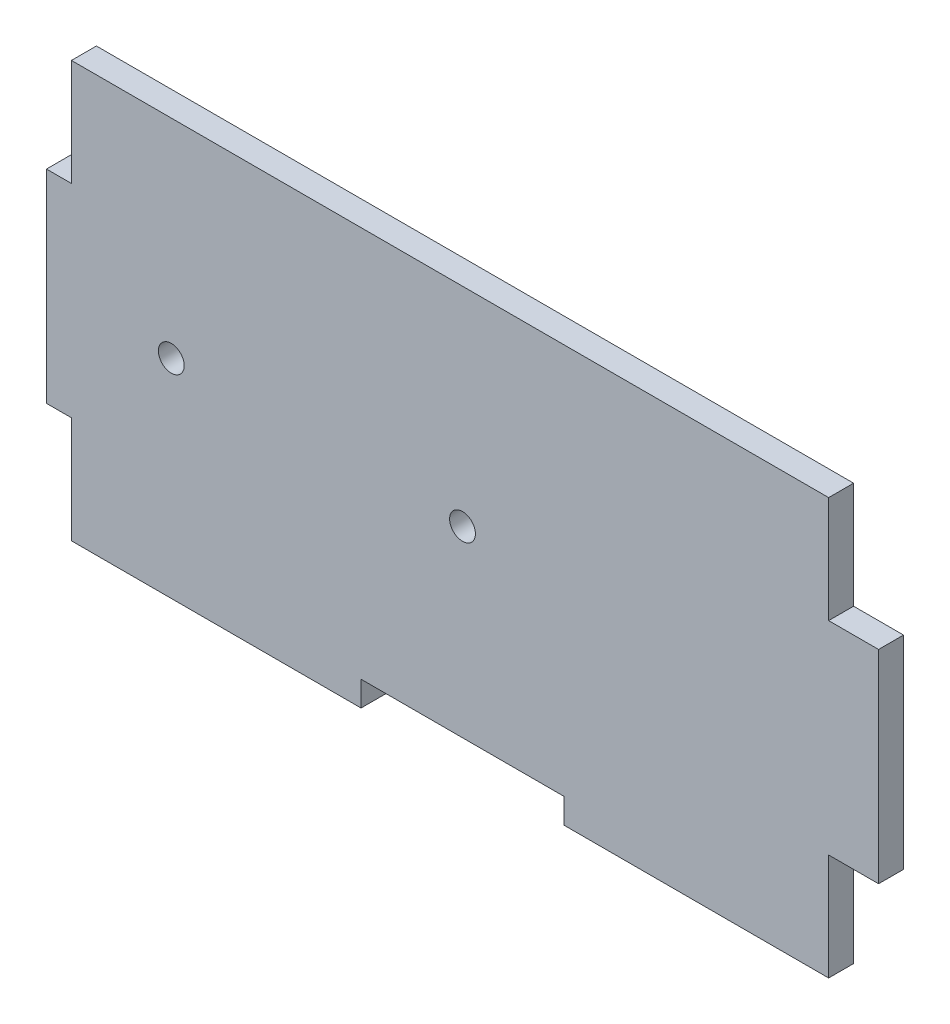
from build123d import *

# Parameters (mm, degrees)
SALIENTE_EXTRUIR1_DEPTH = 3
CROQUIS2_R              = 1.55
CORTAR_EXTRUIR1_DEPTH   = 3
CROQUIS4_W              = 3
CROQUIS4_H              = 12.805
CORTAR_EXTRUIR2_DEPTH   = 10


with BuildPart() as part:
    # Model → Saliente-Extruir1 (new body)
    with BuildSketch(Plane.XY):
        Polygon((186, 103), (186, 90.195), (183, 90.195), (183, 65.805), (186, 65.805), (186, 53), (220.805, 53), (220.805, 56), (245.195, 56), (245.195, 53), (269.585, 53), (280, 53), (280, 65.805), (283, 65.805), (283, 90.195), (280, 90.195), (280, 103), align=None)
    extrude(amount=SALIENTE_EXTRUIR1_DEPTH)

    # Croquis2 → Cortar-Extruir1 (cut)
    with BuildSketch(Plane.XY.offset(3)):
        with Locations((233, 78)):
            Circle(CROQUIS2_R)
        with Locations((198, 78)):
            Circle(CROQUIS2_R)
    extrude(amount=-CORTAR_EXTRUIR1_DEPTH, mode=Mode.SUBTRACT)

    # Croquis4 → Cortar-Extruir2 (cut)
    with BuildSketch(Plane.XY.offset(3)):
        with Locations((278.5, 96.5975)):
            Rectangle(CROQUIS4_W, CROQUIS4_H)
        with Locations((278.5, 59.4025)):
            Rectangle(CROQUIS4_W, CROQUIS4_H)
    extrude(amount=-CORTAR_EXTRUIR2_DEPTH, mode=Mode.SUBTRACT)


solid = part.part
